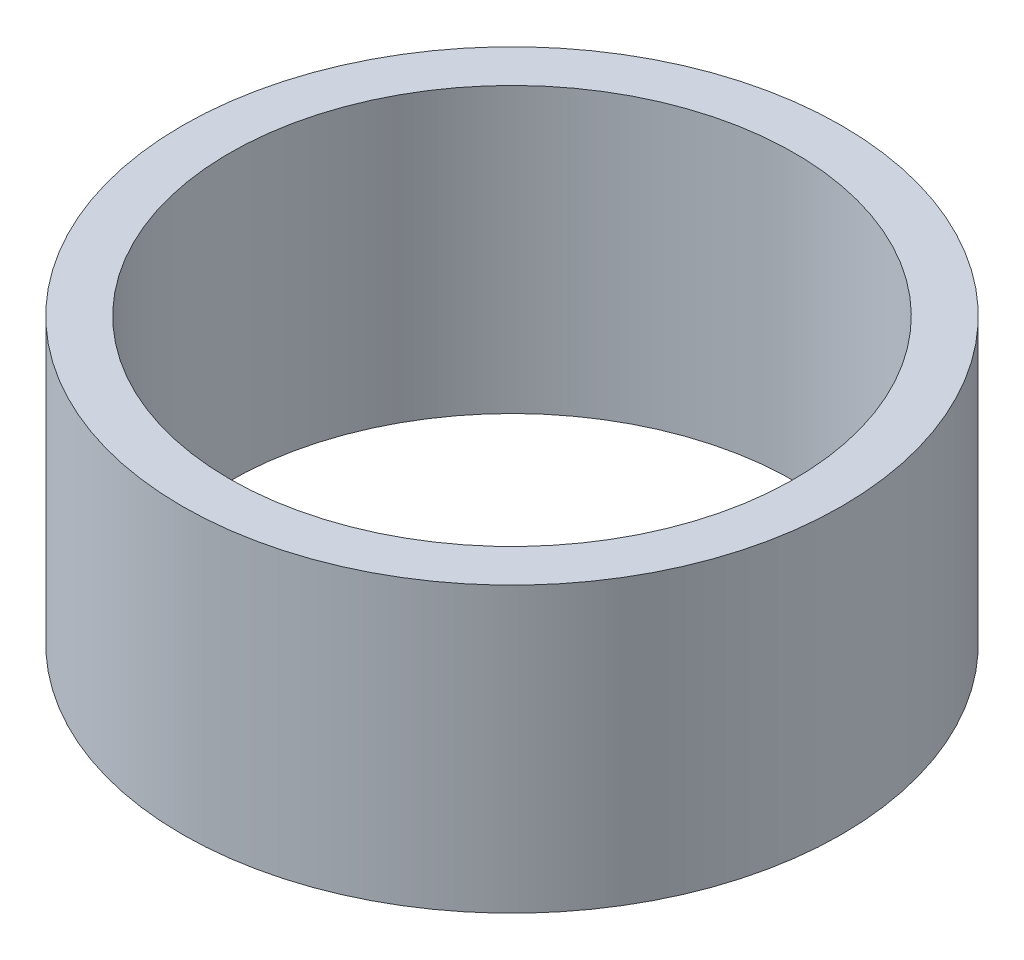
from build123d import *

# Parameters (mm, degrees)
SKETCH1_R           = 13.925
SKETCH1_R_2         = 11.925
BOSS_EXTRUDE1_DEPTH = 12


with BuildPart() as part:
    # Sketch1 → Boss-Extrude1 (new body)
    with BuildSketch(Plane(origin=(0, 0, 0), x_dir=(1, 0, 0), z_dir=(0, 1, 0))):
        Circle(SKETCH1_R)
        Circle(SKETCH1_R_2, mode=Mode.SUBTRACT)
    extrude(amount=BOSS_EXTRUDE1_DEPTH)


solid = part.part
